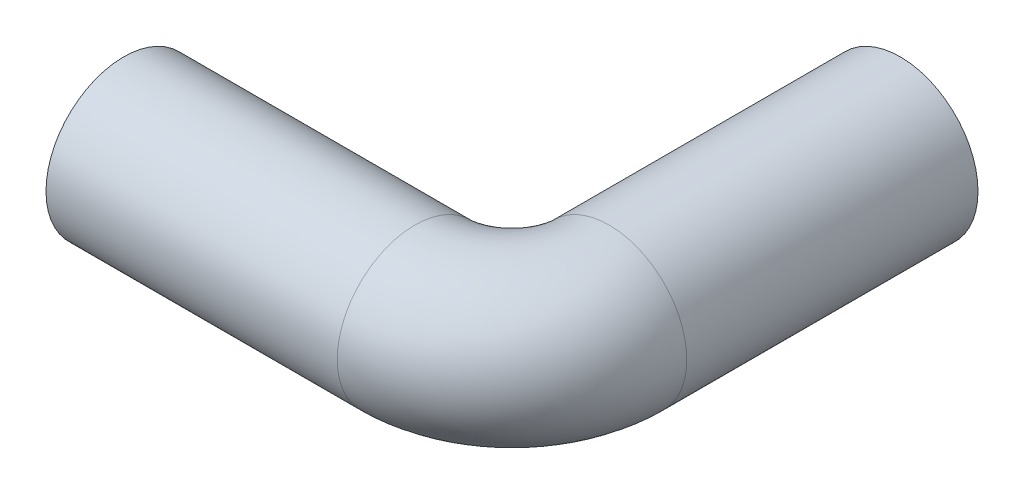
from build123d import *

# Parameters (mm, degrees)
SWEEP_THIN1_PROFILE_R   = 4
SWEEP_THIN1_PROFILE_R_2 = 3.5


with BuildPart() as part:
    # Sweep-Thin1: sweep along a path in Sketch1
    with BuildLine(Plane(origin=(0, 0, 0), x_dir=(1, 0, 0), z_dir=(0, 1, 0))) as sweep_thin1_path:
        Line((0, 0), (15, 0))
        ThreePointArc((15, 0), (18.535533906, 1.464466094), (20, 5))
        Line((20, 5), (20, 20))
    # Sweep-Thin1 profile (on start of the path) → Sweep-Thin1 (sweep)
    with BuildSketch(Plane(origin=(0, 0, 0), x_dir=(0, 0, 1), z_dir=(1, 0, 0))):
        Circle(SWEEP_THIN1_PROFILE_R)
        Circle(SWEEP_THIN1_PROFILE_R_2, mode=Mode.SUBTRACT)
    sweep(path=sweep_thin1_path.line)


solid = part.part
